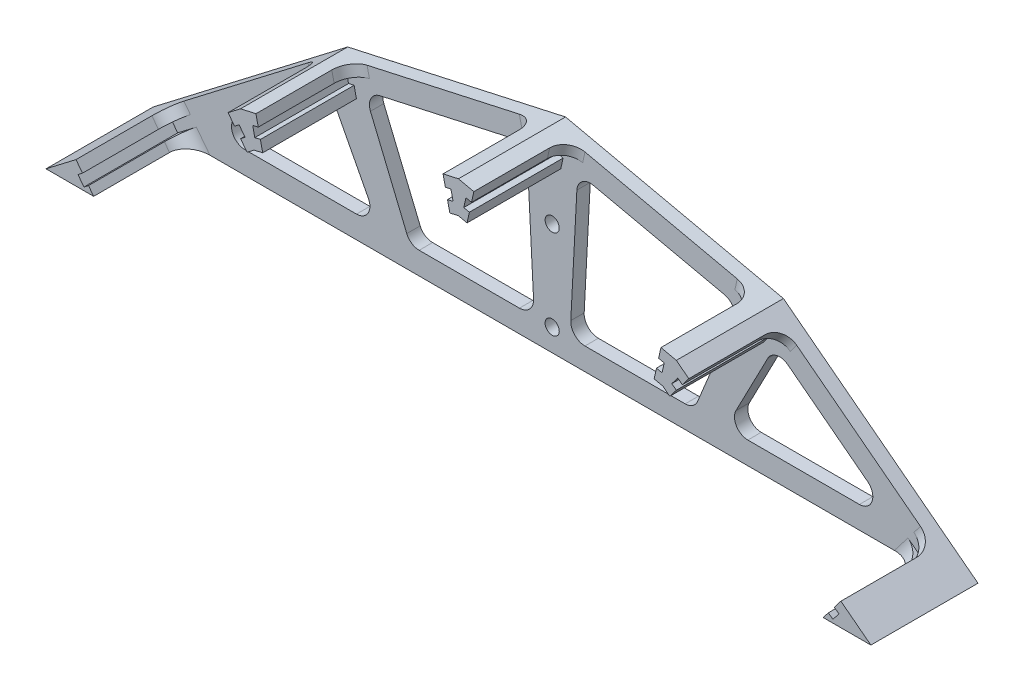
from build123d import *

# Parameters (mm, degrees)
BOSS_EXTRUDE1_DEPTH = 3
BOSS_EXTRUDE2_DEPTH = 21
SKETCH3_R           = 1.5875
CUT_EXTRUDE1_DEPTH  = 111.972114009
FILLET3_R           = 4
FILLET4_R           = 4


with BuildPart() as part:
    # Sketch1 → Boss-Extrude1 (new body)
    with BuildSketch(Plane.XY):
        Polygon((0, 57.752828942), (48.814800356, 46.930848245), (88.482467371, 16.492776794), (92.403575887, 13.484004407), (84.489061716, 13.484004407), (-84.489061716, 13.484004407), (-92.403575887, 13.484004407), (-88.482467371, 16.492776794), (-48.814800356, 46.930848245), align=None)
    extrude(amount=BOSS_EXTRUDE1_DEPTH)

    # Sketch2 → Boss-Extrude2 (add)
    with BuildSketch(Plane.XY.offset(3)):
        Polygon((-45.368475451, 47.694880082), (-48.814800356, 46.930848245), (-51.615337647, 44.781920401), (-50.154310218, 42.877872384), (-49.138817942, 43.657087013), (-47.799542798, 41.911709664), (-48.815035074, 41.132495035), (-47.354007644, 39.228447018), (-45.784645761, 40.432660745), (-43.853398153, 40.860808032), (-44.372853227, 43.203918449), (-45.622512116, 42.926875744), (-46.098679267, 45.074726959), (-44.849020377, 45.351769665), align=None)
        Polygon((0, 57.752828942), (-3.446324905, 56.988797105), (-2.926869832, 54.645686688), (-1.677210943, 54.922729393), (-1.201043792, 52.774878178), (-2.450702681, 52.497835472), (-1.931247608, 50.154725055), (0, 50.582872342), (1.931247608, 50.154725055), (2.450702681, 52.497835472), (1.201043792, 52.774878178), (1.677210943, 54.922729393), (2.926869832, 54.645686688), (3.446324905, 56.988797105), align=None)
        Polygon((-84.22090265, 16.737656622), (-85.681930079, 18.641704639), (-92.403575887, 13.484004407), (-81.724287495, 13.484004407), (-82.881627506, 14.992279274), (-83.897119781, 14.213064644), (-85.236394925, 15.958441993), align=None)
        Polygon((48.814800356, 46.930848245), (45.368475451, 47.694880082), (44.849020377, 45.351769665), (46.098679267, 45.074726959), (45.622512116, 42.926875744), (44.372853227, 43.203918449), (43.853398153, 40.860808032), (45.784645761, 40.432660745), (47.354007644, 39.228447018), (48.815035074, 41.132495035), (47.799542798, 41.911709664), (49.138817942, 43.657087013), (50.154310218, 42.877872384), (51.615337647, 44.781920401), align=None)
        Polygon((82.881627506, 14.992279274), (81.724287495, 13.484004407), (92.403575887, 13.484004407), (85.681930079, 18.641704639), (84.22090265, 16.737656622), (85.236394925, 15.958441993), (83.897119781, 14.213064644), align=None)
    extrude(amount=BOSS_EXTRUDE2_DEPTH)

    # Sketch3 → Cut-Extrude1 (cut, through all)
    with BuildSketch(Plane.XY.offset(3)):
        with Locations((0, 18.484004407)):
            Circle(SKETCH3_R)
        with Locations((0, 38.484004407)):
            Circle(SKETCH3_R)
        with BuildLine():
            Line((-70.662620138, 23.864064428), (-52.799548931, 37.570881053))
            ThreePointArc((-52.799548931, 37.570881053), (-50.323945802, 38.119709054), (-48.312232144, 36.576066872))
            Line((-48.312232144, 36.576066872), (-41.176915041, 22.869250246))
            ThreePointArc((-41.176915041, 22.869250246), (-41.273211929, 19.927684632), (-43.837947541, 18.484004407))
            Line((-43.837947541, 18.484004407), (-68.836335851, 18.484004407))
            ThreePointArc((-68.836335851, 18.484004407), (-71.677126239, 20.519686011), (-70.662620138, 23.864064428))
        make_face()
        with BuildLine():
            Line((-32.570257259, 20.33595411), (-40.714847995, 39.998735523))
            ThreePointArc((-40.714847995, 39.998735523), (-40.604241897, 42.53203166), (-38.592528239, 44.075673842))
            Line((-38.592528239, 44.075673842), (-9.178295063, 50.596652343))
            ThreePointArc((-9.178295063, 50.596652343), (-6.713094257, 50.055770329), (-5.533087617, 47.82477219))
            Line((-5.533087617, 47.82477219), (-4.17050626, 21.825171068))
            ThreePointArc((-4.17050626, 21.825171068), (-5.038091405, 19.473478629), (-7.341155033, 18.484004407))
            Line((-7.341155033, 18.484004407), (-29.798618662, 18.484004407))
            ThreePointArc((-29.798618662, 18.484004407), (-31.465329361, 18.98959557), (-32.570257259, 20.33595411))
        make_face()
        with BuildLine():
            Line((7.341155033, 18.484004407), (29.798618662, 18.484004407))
            ThreePointArc((29.798618662, 18.484004407), (31.465329361, 18.98959557), (32.570257259, 20.33595411))
            Line((32.570257259, 20.33595411), (40.714847995, 39.998735523))
            ThreePointArc((40.714847995, 39.998735523), (40.604241897, 42.53203166), (38.592528239, 44.075673842))
            Line((38.592528239, 44.075673842), (9.178295063, 50.596652343))
            ThreePointArc((9.178295063, 50.596652343), (6.713094257, 50.055770329), (5.533087617, 47.82477219))
            Line((5.533087617, 47.82477219), (4.17050626, 21.825171068))
            ThreePointArc((4.17050626, 21.825171068), (5.038091405, 19.473478629), (7.341155033, 18.484004407))
        make_face()
        with BuildLine():
            Line((43.837947541, 18.484004407), (68.836335851, 18.484004407))
            ThreePointArc((68.836335851, 18.484004407), (71.677126239, 20.519686011), (70.662620138, 23.864064428))
            Line((70.662620138, 23.864064428), (52.799548931, 37.570881053))
            ThreePointArc((52.799548931, 37.570881053), (50.323945802, 38.119709054), (48.312232144, 36.576066872))
            Line((48.312232144, 36.576066872), (41.176915041, 22.869250246))
            ThreePointArc((41.176915041, 22.869250246), (41.273211929, 19.927684632), (43.837947541, 18.484004407))
        make_face()
    extrude(amount=-CUT_EXTRUDE1_DEPTH, mode=Mode.SUBTRACT)

    # Fillet3
    fillet3_edges = [part.edges().sort_by_distance(p)[0] for p in [
        (-84.951416365, 17.689680631, 3),
    ]]
    fillet(fillet3_edges, radius=FILLET3_R)

    # Fillet4
    fillet4_edges = [part.edges().sort_by_distance(p)[0] for p in [
        (84.951416365, 17.689680631, 3),
        (50.884823932, 43.829896392, 3),
        (45.108747914, 46.523324874, 3),
        (3.186597368, 55.817241896, 3),
        (-3.186597368, 55.817241896, 3),
        (-45.108747914, 46.523324874, 3),
        (-82.302957501, 14.23814184, 3),
        (-50.884823932, 43.829896392, 3),
        (82.302957501, 14.23814184, 3),
    ]]
    fillet(fillet4_edges, radius=FILLET4_R)


solid = part.part
